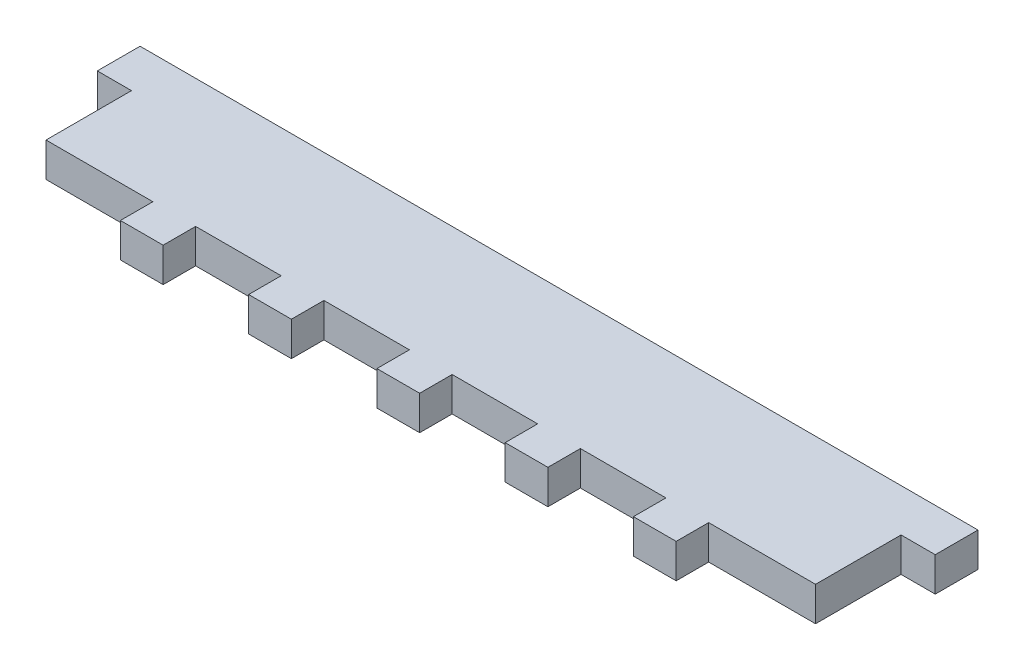
from build123d import *

# Parameters (mm, degrees)
BOSS_EXTRUDE1_DEPTH = 5.08
SKETCH2_W           = 6.35
SKETCH2_H           = 5.08
BOSS_EXTRUDE2_DEPTH = 4.826
LPATTERN1_COUNT     = 5
LPATTERN1_PITCH     = 19.05


with BuildPart() as part:
    # Sketch1 → Boss-Extrude1 (new body)
    with BuildSketch(Plane(origin=(0, 0, 0), x_dir=(1, 0, 0), z_dir=(0, 1, 0))):
        Polygon((0, 0), (114.3, 0), (114.3, 12.7), (119.38, 12.7), (119.38, 19.05), (114.3, 19.05), (0, 19.05), (-5.08, 19.05), (-5.08, 12.7), (0, 12.7), align=None)
    extrude(amount=BOSS_EXTRUDE1_DEPTH)

    # Sketch2 → Boss-Extrude2 (add)
    with BuildSketch(Plane.XY):
        with Locations((19.05, 2.54)):
            Rectangle(SKETCH2_W, SKETCH2_H)
    boss_extrude2 = extrude(amount=BOSS_EXTRUDE2_DEPTH)

    # LPattern1: Boss-Extrude2 ×5
    with Locations(*[(i * LPATTERN1_PITCH, 0, 0) for i in range(1, LPATTERN1_COUNT)]):
        add(boss_extrude2)


solid = part.part
